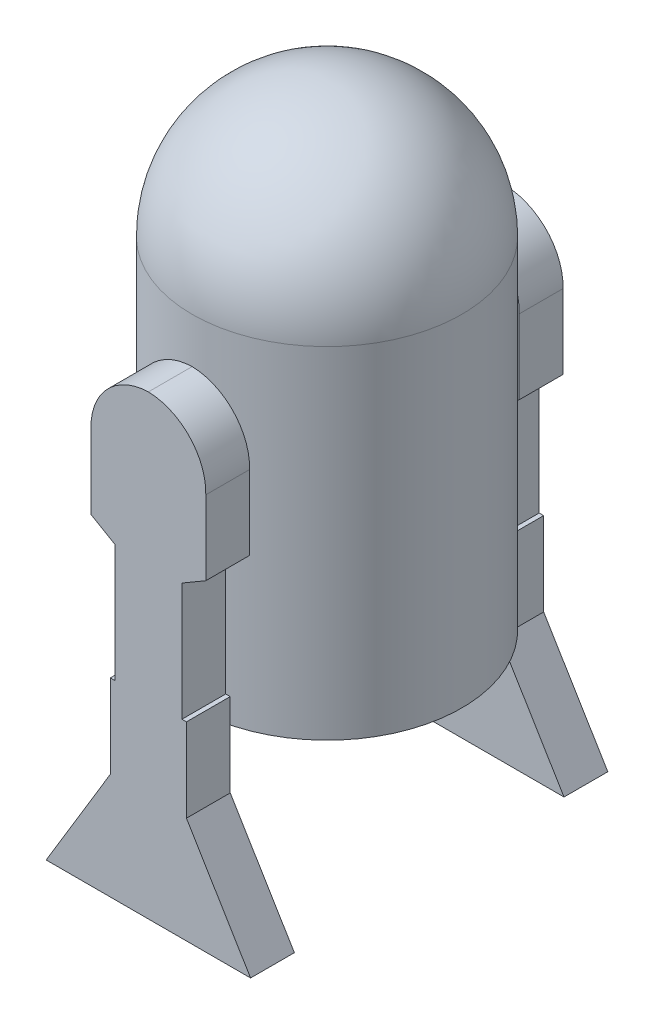
from build123d import *

# Parameters (mm, degrees)
BOSS_EXTRUDE1_DEPTH = 75


with BuildPart() as part:
    # Sketch1 → Revolve1 (revolve)
    with BuildSketch(Plane(origin=(0, 0, 0), x_dir=(0, 0, -1), z_dir=(1, 0, 0))):
        Polygon((0, 786.767092044), (230.869874895, 786.767092044), (230.869874895, 278.028274446), (169.988720126, 278.028274446), (132.067656697, 219.189571635), (0, 219.189571635), align=None)
    revolve(axis=Axis((0, 219.189571635, 0), (0, 1, 0)))

    # Sketch2 → Revolve3 (revolve)
    with BuildSketch(Plane(origin=(0, 0, 0), x_dir=(0, 0, -1), z_dir=(1, 0, 0))):
        with BuildLine():
            ThreePointArc((-230.869874895, 861.767092044), (-163.24965411, 1025.016746154), (0, 1092.636966939))
            Line((0, 1092.636966939), (0, 786.767092044))
            Line((0, 786.767092044), (-230.869874895, 786.767092044))
            Line((-230.869874895, 786.767092044), (-230.869874895, 861.767092044))
        make_face()
    revolve(axis=Axis((0, 786.767092044, 0), (0, -1, 0)))


with BuildPart() as body_2:
    # Sketch7 → Boss-Extrude1 (new body)
    with BuildSketch(Plane(origin=(0, 0, -230.869874895), x_dir=(-1, 0, 0), z_dir=(0, 0, -1))):
        with BuildLine():
            Line((98.30284319, 680.831919222), (98.30284319, 553.465340718))
            Line((98.30284319, 553.465340718), (57.443091038, 529.595182603))
            Line((57.443091038, 529.595182603), (57.443091038, 327.575952081))
            Line((57.443091038, 327.575952081), (65.151727755, 327.575952081))
            Line((65.151727755, 327.575952081), (65.151727755, 184.684592199))
            Line((65.151727755, 184.684592199), (175, 2.636966939))
            Line((175, 2.636966939), (-175, 2.636966939))
            Line((-175, 2.636966939), (-65.151727755, 184.684592199))
            Line((-65.151727755, 184.684592199), (-65.151727755, 327.575952081))
            Line((-65.151727755, 327.575952081), (-57.443091038, 327.575952081))
            Line((-57.443091038, 327.575952081), (-57.443091038, 529.595182603))
            Line((-57.443091038, 529.595182603), (-98.30284319, 553.465340718))
            Line((-98.30284319, 553.465340718), (-98.30284319, 680.831919222))
            ThreePointArc((-98.30284319, 680.831919222), (-70.596182709, 752.96333778), (0, 784.376385469))
            ThreePointArc((0, 784.376385469), (70.596182709, 752.96333778), (98.30284319, 680.831919222))
        make_face()
    extrude(amount=BOSS_EXTRUDE1_DEPTH)


with BuildPart() as body_3:
    # Mirror18: mirrored copy
    add(body_2.part.mirror(Plane.XY))


solid = Compound([part.part, body_2.part, body_3.part])
